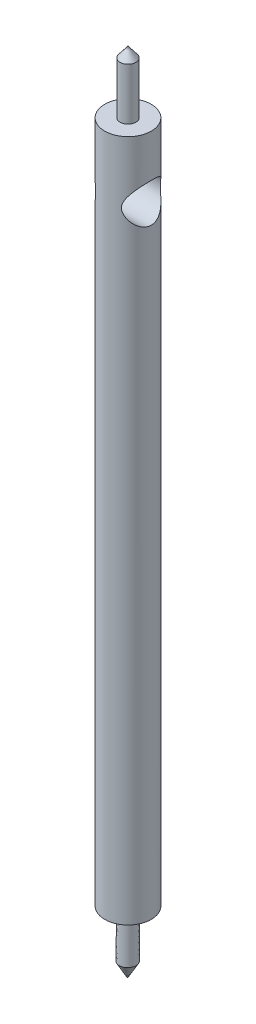
from build123d import *

# Parameters (mm, degrees)
SKETCH1_R               = 2.38125
BOSS_EXTRUDE1_DEPTH     = 69.85
SKETCH7_R               = 1.984375
CUT_EXTRUDE1_DEPTH      = 3.38125
CUT_EXTRUDE1_DEPTH_BACK = 3.38125


with BuildPart() as part:
    # Sketch1 → Boss-Extrude1 (new body)
    with BuildSketch(Plane(origin=(0, 0, 0), x_dir=(1, 0, 0), z_dir=(0, 1, 0))):
        Circle(SKETCH1_R)
    extrude(amount=BOSS_EXTRUDE1_DEPTH)

    # Sketch2 → Revolve4 (revolve)
    with BuildSketch(Plane.XY):
        Polygon((0, 76.2), (0, 69.85), (0.8128, 69.85), (0.8128, 75.157753569), align=None)
    revolve(axis=Axis((0, 79.243977314, 0), (0, -1, 0)))

    # Sketch4 → Revolve5 (revolve)
    with BuildSketch(Plane(origin=(0, 0, 0), x_dir=(0, 0, -1), z_dir=(1, 0, 0))):
        Polygon((0, 0), (-0.054059899, -6.35), (0.8128, -4.848554612), (0.8128, 0), align=None)
    revolve(axis=Axis((0, 0, 0), (0, -0.999963763, 0.008513061)))

    # Sketch7 → Cut-Extrude1 (cut, two sides)
    with BuildSketch(Plane(origin=(0, 0, 0), x_dir=(0, 0, -1), z_dir=(1, 0, 0))) as cut_extrude1_sk:
        with Locations((0, 63.5)):
            Circle(SKETCH7_R)
    extrude(amount=CUT_EXTRUDE1_DEPTH, mode=Mode.SUBTRACT)
    extrude(cut_extrude1_sk.sketch, amount=-CUT_EXTRUDE1_DEPTH_BACK, mode=Mode.SUBTRACT)


solid = part.part
